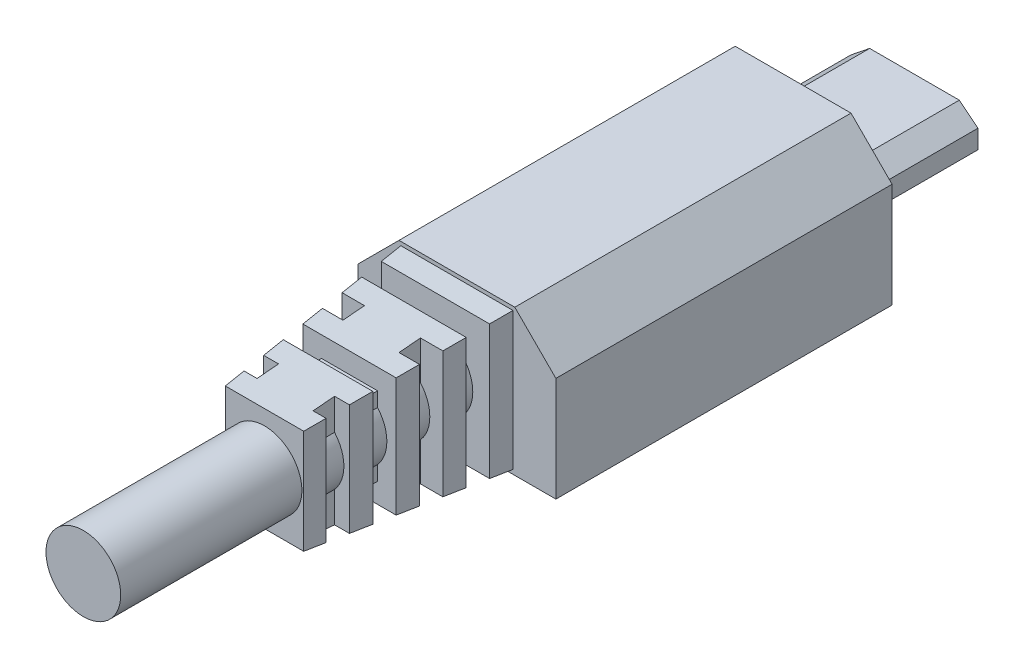
from build123d import *

# Parameters (mm, degrees)
SKETCH1_W           = 3.7
SKETCH1_H           = 0.65
BOSS_EXTRUDE1_DEPTH = 6.5
SKETCH2_W           = 3.7
SKETCH2_H           = 0.65
BOSS_EXTRUDE2_DEPTH = 18
SKETCH5_W           = 6
SKETCH5_H           = 7.371976581
BOSS_EXTRUDE4_DEPTH = 10.3
BOSS_EXTRUDE4_TAPER = 5
SKETCH7_W           = 2.169554373
SKETCH7_H           = 1.15
CUT_EXTRUDE1_DEPTH  = 10.3
SKETCH9_W           = 1.15
SKETCH9_H           = 1.6
CUT_EXTRUDE2_DEPTH  = 10.3
SKETCH3_R           = 2
BOSS_EXTRUDE3_DEPTH = 20


with BuildPart() as part:
    # Sketch1 → Boss-Extrude1 (new body)
    with BuildSketch(Plane.XY):
        Polygon((1, 1.8), (0, 1), (0, 0), (6.8, 0), (6.8, 1), (5.8, 1.8), align=None)
        with Locations((3.4, 0.525)):
            Rectangle(SKETCH1_W, SKETCH1_H, mode=Mode.SUBTRACT)
    extrude(amount=BOSS_EXTRUDE1_DEPTH)

    # Sketch2 → Boss-Extrude2 (add)
    with BuildSketch(Plane.XY.offset(6.5)):
        Polygon((6.5, 4.8), (0.3, 4.8), (-1.9, 2.6), (-1.9, -3), (8.7, -3), (8.7, 2.6), align=None)
        Polygon((5.8, 1.8), (6.8, 1), (6.8, 0), (0, 0), (0, 1), (1, 1.8), align=None, mode=Mode.SUBTRACT)
        Polygon((6.8, 0), (6.8, 1), (5.8, 1.8), (1, 1.8), (0, 1), (0, 0), align=None)
        with Locations((3.4, 0.525)):
            Rectangle(SKETCH2_W, SKETCH2_H, mode=Mode.SUBTRACT)
        with Locations((3.4, 0.525)):
            Rectangle(SKETCH2_W, SKETCH2_H)
    extrude(amount=BOSS_EXTRUDE2_DEPTH)

    # Sketch5 → Boss-Extrude4 (add)
    with BuildSketch(Plane.XY.offset(24.5)):
        with Locations((3.4, 0.91401171)):
            Rectangle(SKETCH5_W, SKETCH5_H)
    extrude(amount=BOSS_EXTRUDE4_DEPTH, taper=BOSS_EXTRUDE4_TAPER)

    # Sketch7 → Cut-Extrude1 (cut)
    with BuildSketch(Plane(origin=(0, 4.8, 0), x_dir=(1, 0, 0), z_dir=(0, 1, 0))):
        Polygon((1.9, -25.65), (0.3, -25.65), (-0.269554373, -25.65), (-0.269554373, -26.8), (1.9, -26.8), align=None)
        with Locations((0.815222814, -28.525)):
            Rectangle(SKETCH7_W, SKETCH7_H)
        with Locations((0.815222814, -30.825)):
            Rectangle(SKETCH7_W, SKETCH7_H)
        with Locations((0.815222814, -33.125)):
            Rectangle(SKETCH7_W, SKETCH7_H)
        with Locations((5.984777187, -26.225)):
            Rectangle(SKETCH7_W, SKETCH7_H)
        with Locations((5.984777187, -28.525)):
            Rectangle(SKETCH7_W, SKETCH7_H)
        with Locations((5.984777187, -30.825)):
            Rectangle(SKETCH7_W, SKETCH7_H)
        with Locations((5.984777187, -33.125)):
            Rectangle(SKETCH7_W, SKETCH7_H)
    extrude(amount=-CUT_EXTRUDE1_DEPTH, mode=Mode.SUBTRACT)

    # Sketch9 → Cut-Extrude2 (cut)
    with BuildSketch(Plane(origin=(8.7, 0, 0), x_dir=(0, 0, -1), z_dir=(1, 0, 0))):
        with Locations((-26.225, 3.8)):
            Rectangle(SKETCH9_W, SKETCH9_H)
        with Locations((-30.825, 3.8)):
            Rectangle(SKETCH9_W, SKETCH9_H)
        with Locations((-26.225, -2)):
            Rectangle(SKETCH9_W, SKETCH9_H)
        with Locations((-30.825, -2)):
            Rectangle(SKETCH9_W, SKETCH9_H)
    extrude(amount=-CUT_EXTRUDE2_DEPTH, mode=Mode.SUBTRACT)

    # Sketch3 → Boss-Extrude3 (add)
    with BuildSketch(Plane.XY.offset(24.5)):
        with Locations((3.4, 0.9)):
            Circle(SKETCH3_R)
    extrude(amount=BOSS_EXTRUDE3_DEPTH)


solid = part.part
